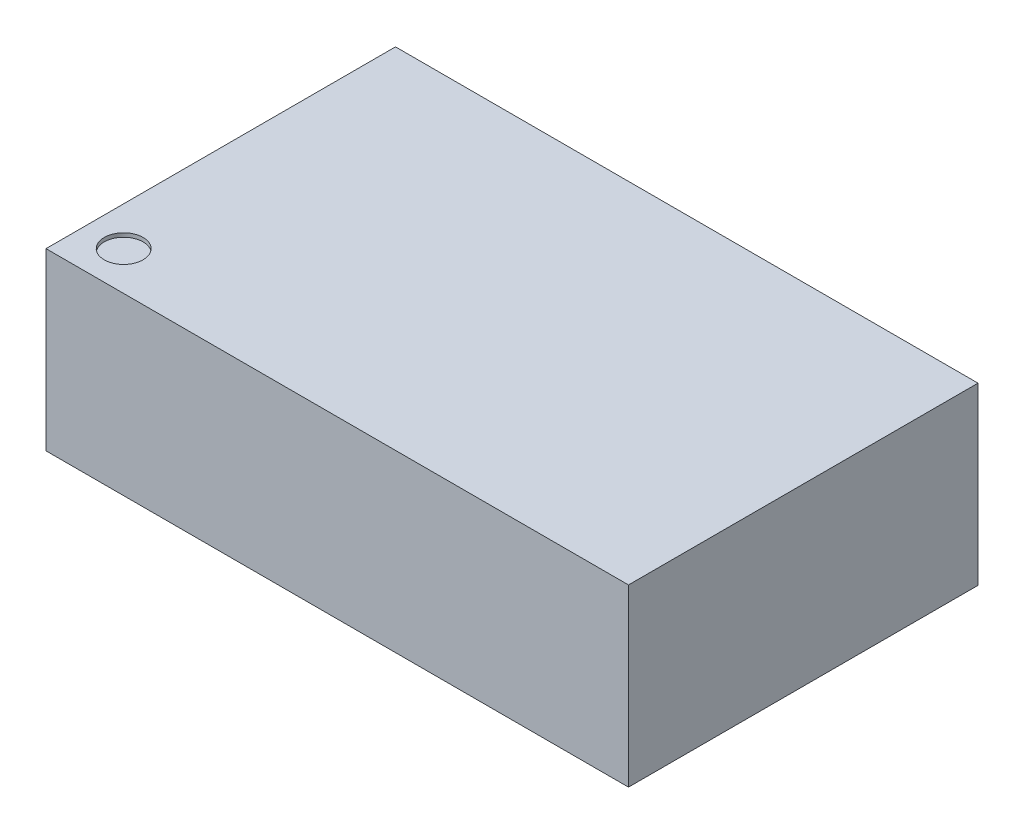
from build123d import *

# Parameters (mm, degrees)
SKETCH1_W           = 15
SKETCH1_H           = 9
BOSS_EXTRUDE1_DEPTH = 4.51
SKETCH2_R           = 0.5
CUT_EXTRUDE1_DEPTH  = 0.1


with BuildPart() as part:
    # Sketch1 → Boss-Extrude1 (new body)
    with BuildSketch(Plane(origin=(0, 0, 0), x_dir=(1, 0, 0), z_dir=(0, 1, 0))):
        Rectangle(SKETCH1_W, SKETCH1_H)
    extrude(amount=BOSS_EXTRUDE1_DEPTH)

    # Sketch2 → Cut-Extrude1 (cut)
    with BuildSketch(Plane(origin=(0, 4.51, 0), x_dir=(1, 0, 0), z_dir=(0, 1, 0))):
        with Locations((-6.5, -3.5)):
            Circle(SKETCH2_R)
    extrude(amount=-CUT_EXTRUDE1_DEPTH, mode=Mode.SUBTRACT)


solid = part.part
